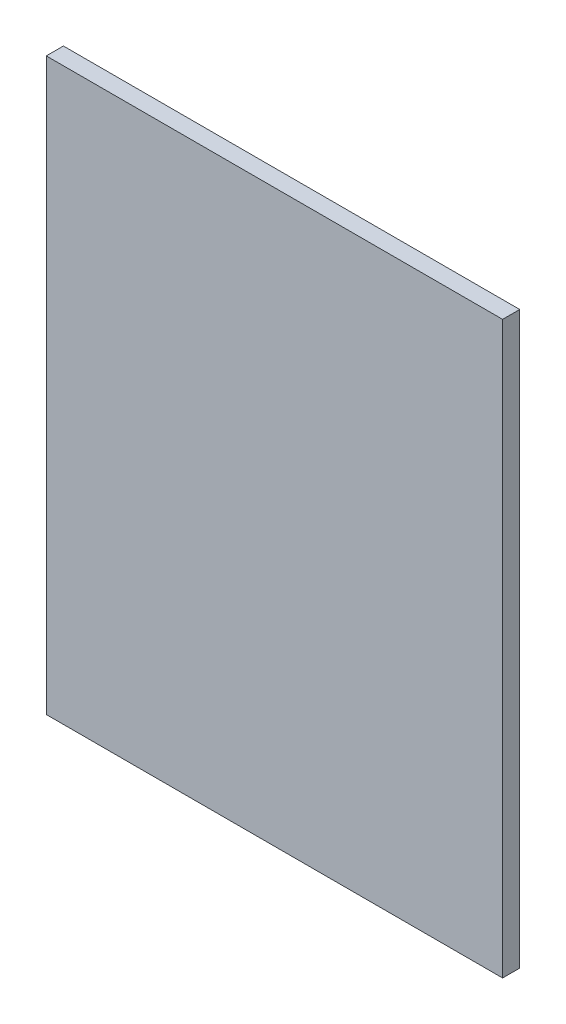
from build123d import *

# Parameters (mm, degrees)
ESBO_O1_W                = 80
ESBO_O1_H                = 100
RESSALTO_EXTRUS_O1_DEPTH = 3


with BuildPart() as part:
    # Esboço1 → Ressalto-extrusão1 (new body)
    with BuildSketch(Plane.XY):
        with Locations((15.56043956, -38.879120879)):
            Rectangle(ESBO_O1_W, ESBO_O1_H)
    extrude(amount=RESSALTO_EXTRUS_O1_DEPTH)


solid = part.part
